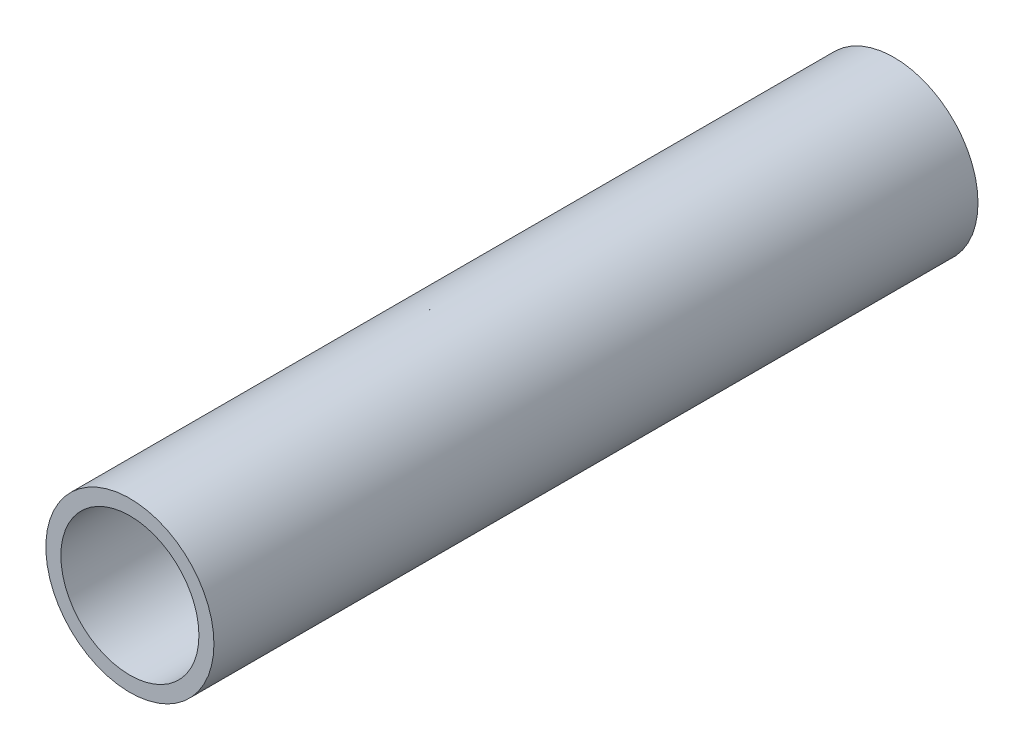
from build123d import *

# Parameters (mm, degrees)
SKETCH1_R           = 2.794
SKETCH1_R_2         = 2.295
BOSS_EXTRUDE1_DEPTH = 25.4
SKETCH4_R           = 2.295
SKETCH4_R_2         = 1.778
BOSS_EXTRUDE2_DEPTH = 0.635


with BuildPart() as part:
    # Sketch1 → Boss-Extrude1 (new body)
    with BuildSketch(Plane.XY):
        Circle(SKETCH1_R)
        Circle(SKETCH1_R_2, mode=Mode.SUBTRACT)
    extrude(amount=BOSS_EXTRUDE1_DEPTH)

    # Sketch4 → Boss-Extrude2 (add)
    with BuildSketch(Plane(origin=(0, 0, 9.652), x_dir=(-1, 0, 0), z_dir=(0, 0, -1))):
        Circle(SKETCH4_R)
        Circle(SKETCH4_R_2, mode=Mode.SUBTRACT)
    extrude(amount=BOSS_EXTRUDE2_DEPTH)


solid = part.part
